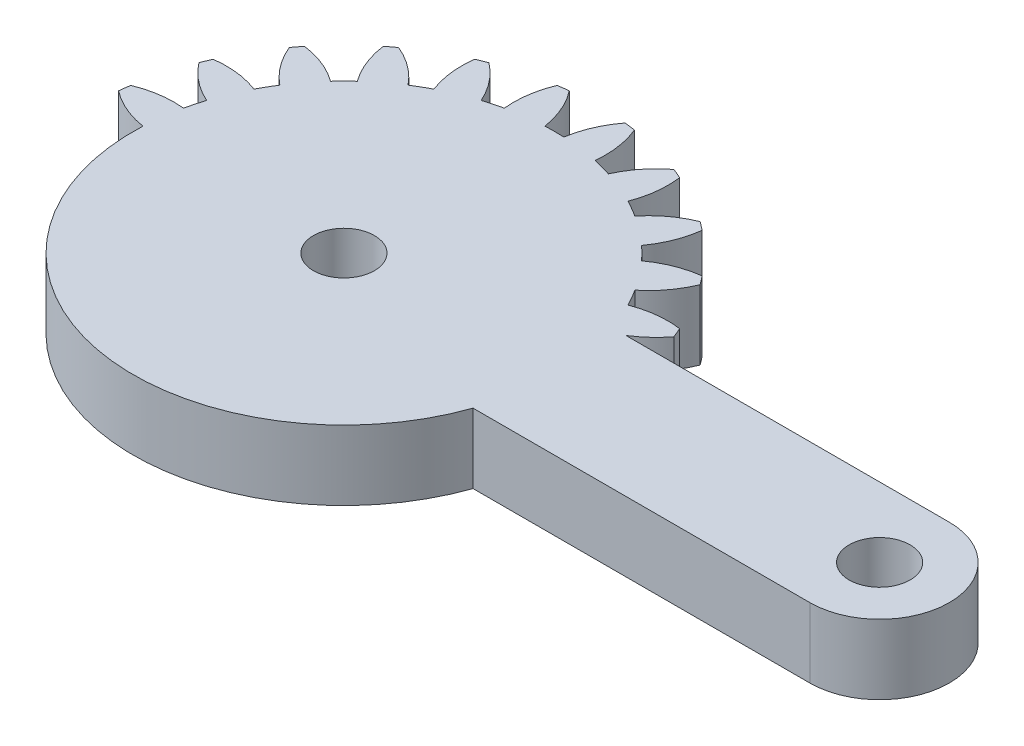
from build123d import *

# Parameters (mm, degrees)
SKETCH1_R           = 1.75
BOSS_EXTRUDE1_DEPTH = 4
CUT_EXTRUDE1_DEPTH  = 10


with BuildPart() as part:
    # Sketch1 → Boss-Extrude1 (new body)
    with BuildSketch(Plane(origin=(0, 0, 0), x_dir=(1, 0, 0), z_dir=(0, 1, 0))):
        with BuildLine():
            Line((20.643657446, 4), (2.081641936, 4))
            ThreePointArc((2.081641936, 4), (2.861028333, 4.588201733), (3.521749436, 5.30713988))
            ThreePointArc((3.521749436, 5.30713988), (3.405395609, 5.596745198), (3.282888305, 5.883801663))
            ThreePointArc((3.282888305, 5.883801663), (1.93527598, 5.894040025), (0.627094961, 5.57027124))
            ThreePointArc((0.627094961, 5.57027124), (0.366286148, 6.046375), (0.084372603, 6.510293938))
            ThreePointArc((0.084372603, 6.510293938), (1.018855105, 7.48132754), (1.683794586, 8.65351323))
            ThreePointArc((1.683794586, 8.65351323), (1.496450048, 8.903135899), (1.303821399, 9.148703928))
            ThreePointArc((1.303821399, 9.148703928), (-0.000522033, 8.809805691), (-1.180330337, 8.158486898))
            ThreePointArc((-1.180330337, 8.158486898), (-1.555477026, 8.550865528), (-1.947855656, 8.926012217))
            ThreePointArc((-1.947855656, 8.926012217), (-1.296536862, 10.105820521), (-0.957638625, 11.410163953))
            ThreePointArc((-0.957638625, 11.410163953), (-1.203206655, 11.602792602), (-1.452829324, 11.79013714))
            ThreePointArc((-1.452829324, 11.79013714), (-2.625015014, 11.125197659), (-3.596048616, 10.190715157))
            ThreePointArc((-3.596048616, 10.190715157), (-4.059967554, 10.472628702), (-4.536071314, 10.733437515))
            ThreePointArc((-4.536071314, 10.733437515), (-4.212302529, 12.041618533), (-4.222540891, 13.389230859))
            ThreePointArc((-4.222540891, 13.389230859), (-4.509597355, 13.511738163), (-4.799202674, 13.62809199))
            ThreePointArc((-4.799202674, 13.62809199), (-5.759348103, 12.682425791), (-6.455432668, 11.528463019))
            ThreePointArc((-6.455432668, 11.528463019), (-6.976508546, 11.680699536), (-7.503891752, 11.809396783))
            ThreePointArc((-7.503891752, 11.809396783), (-7.529737283, 13.156800143), (-7.888414517, 14.455843809))
            ThreePointArc((-7.888414517, 14.455843809), (-8.197396993, 14.499881098), (-8.507248835, 14.537314892))
            ThreePointArc((-8.507248835, 14.537314892), (-9.18992168, 13.375367565), (-9.563620196, 12.080565177))
            ThreePointArc((-9.563620196, 12.080565177), (-10.106342554, 12.09275), (-10.649064912, 12.080565177))
            ThreePointArc((-10.649064912, 12.080565177), (-11.022763428, 13.375367565), (-11.705436272, 14.537314892))
            ThreePointArc((-11.705436272, 14.537314892), (-12.015288115, 14.499881098), (-12.324270591, 14.455843809))
            ThreePointArc((-12.324270591, 14.455843809), (-12.682947825, 13.156800143), (-12.708793355, 11.809396783))
            ThreePointArc((-12.708793355, 11.809396783), (-13.236176561, 11.680699536), (-13.757252439, 11.528463019))
            ThreePointArc((-13.757252439, 11.528463019), (-14.453337005, 12.682425791), (-15.413482434, 13.62809199))
            ThreePointArc((-15.413482434, 13.62809199), (-15.703087752, 13.511738163), (-15.990144217, 13.389230859))
            ThreePointArc((-15.990144217, 13.389230859), (-16.000382579, 12.041618533), (-15.676613793, 10.733437515))
            ThreePointArc((-15.676613793, 10.733437515), (-16.152717554, 10.472628702), (-16.616636492, 10.190715157))
            ThreePointArc((-16.616636492, 10.190715157), (-17.587670094, 11.125197659), (-18.759855783, 11.79013714))
            ThreePointArc((-18.759855783, 11.79013714), (-19.009478453, 11.602792602), (-19.255046482, 11.410163953))
            ThreePointArc((-19.255046482, 11.410163953), (-18.916148245, 10.105820521), (-18.264829452, 8.926012217))
            ThreePointArc((-18.264829452, 8.926012217), (-18.657208082, 8.550865528), (-19.032354771, 8.158486898))
            ThreePointArc((-19.032354771, 8.158486898), (-20.212163074, 8.809805691), (-21.516506507, 9.148703928))
            ThreePointArc((-21.516506507, 9.148703928), (-21.709135156, 8.903135899), (-21.896479694, 8.65351323))
            ThreePointArc((-21.896479694, 8.65351323), (-21.231540213, 7.48132754), (-20.297057711, 6.510293938))
            ThreePointArc((-20.297057711, 6.510293938), (-20.578971255, 6.046375), (-20.839780068, 5.57027124))
            ThreePointArc((-20.839780068, 5.57027124), (-22.147961087, 5.894040025), (-23.495573413, 5.883801663))
            ThreePointArc((-23.495573413, 5.883801663), (-23.618080717, 5.596745198), (-23.734434544, 5.30713988))
            ThreePointArc((-23.734434544, 5.30713988), (-22.788768345, 4.346994451), (-21.634805572, 3.650909885))
            ThreePointArc((-21.634805572, 3.650909885), (-21.78704209, 3.129834008), (-21.915739337, 2.602450802))
            ThreePointArc((-21.915739337, 2.602450802), (-23.263142697, 2.576605271), (-24.562186363, 2.217928037))
            ThreePointArc((-24.562186363, 2.217928037), (-24.606223651, 1.908945561), (-24.643657446, 1.599093719))
            ThreePointArc((-24.643657446, 1.599093719), (-23.481710119, 0.916420874), (-22.186907731, 0.542722358))
            ThreePointArc((-22.186907731, 0.542722358), (-22.199092554, 0), (-22.186907731, -0.542722358))
            ThreePointArc((-22.186907731, -0.542722358), (-23.481710119, -0.916420874), (-24.643657446, -1.599093719))
            ThreePointArc((-24.643657446, -1.599093719), (-24.606223651, -1.908945561), (-24.562186363, -2.217928037))
            ThreePointArc((-24.562186363, -2.217928037), (-23.263142697, -2.576605271), (-21.915739337, -2.602450802))
            ThreePointArc((-21.915739337, -2.602450802), (-21.78704209, -3.129834008), (-21.634805572, -3.650909885))
            ThreePointArc((-21.634805572, -3.650909885), (-22.788768345, -4.346994451), (-23.734434544, -5.30713988))
            ThreePointArc((-23.734434544, -5.30713988), (-23.618080717, -5.596745198), (-23.495573413, -5.883801663))
            ThreePointArc((-23.495573413, -5.883801663), (-22.147961087, -5.894040025), (-20.839780068, -5.57027124))
            ThreePointArc((-20.839780068, -5.57027124), (-20.578971255, -6.046375), (-20.297057711, -6.510293938))
            ThreePointArc((-20.297057711, -6.510293938), (-21.231540213, -7.48132754), (-21.896479694, -8.65351323))
            ThreePointArc((-21.896479694, -8.65351323), (-21.709135156, -8.903135899), (-21.516506507, -9.148703928))
            ThreePointArc((-21.516506507, -9.148703928), (-20.212163074, -8.809805691), (-19.032354771, -8.158486898))
            ThreePointArc((-19.032354771, -8.158486898), (-18.657208082, -8.550865528), (-18.264829452, -8.926012217))
            ThreePointArc((-18.264829452, -8.926012217), (-18.916148245, -10.105820521), (-19.255046482, -11.410163953))
            ThreePointArc((-19.255046482, -11.410163953), (-19.009478453, -11.602792602), (-18.759855783, -11.79013714))
            ThreePointArc((-18.759855783, -11.79013714), (-17.587670094, -11.125197659), (-16.616636492, -10.190715157))
            ThreePointArc((-16.616636492, -10.190715157), (-16.152717554, -10.472628702), (-15.676613793, -10.733437515))
            ThreePointArc((-15.676613793, -10.733437515), (-16.000382579, -12.041618533), (-15.990144217, -13.389230859))
            ThreePointArc((-15.990144217, -13.389230859), (-15.703087752, -13.511738163), (-15.413482434, -13.62809199))
            ThreePointArc((-15.413482434, -13.62809199), (-14.453337005, -12.682425791), (-13.757252439, -11.528463019))
            ThreePointArc((-13.757252439, -11.528463019), (-13.236176561, -11.680699536), (-12.708793355, -11.809396783))
            ThreePointArc((-12.708793355, -11.809396783), (-12.682947825, -13.156800143), (-12.324270591, -14.455843809))
            ThreePointArc((-12.324270591, -14.455843809), (-12.015288115, -14.499881098), (-11.705436272, -14.537314892))
            ThreePointArc((-11.705436272, -14.537314892), (-11.022763428, -13.375367565), (-10.649064912, -12.080565177))
            ThreePointArc((-10.649064912, -12.080565177), (-10.106342554, -12.09275), (-9.563620196, -12.080565177))
            ThreePointArc((-9.563620196, -12.080565177), (-9.18992168, -13.375367565), (-8.507248835, -14.537314892))
            ThreePointArc((-8.507248835, -14.537314892), (-8.197396993, -14.499881098), (-7.888414517, -14.455843809))
            ThreePointArc((-7.888414517, -14.455843809), (-7.529737283, -13.156800143), (-7.503891752, -11.809396783))
            ThreePointArc((-7.503891752, -11.809396783), (-6.976508546, -11.680699536), (-6.455432668, -11.528463019))
            ThreePointArc((-6.455432668, -11.528463019), (-5.759348103, -12.682425791), (-4.799202674, -13.62809199))
            ThreePointArc((-4.799202674, -13.62809199), (-4.509597355, -13.511738163), (-4.222540891, -13.389230859))
            ThreePointArc((-4.222540891, -13.389230859), (-4.212302529, -12.041618533), (-4.536071314, -10.733437515))
            ThreePointArc((-4.536071314, -10.733437515), (-4.059967554, -10.472628702), (-3.596048616, -10.190715157))
            ThreePointArc((-3.596048616, -10.190715157), (-2.625015014, -11.125197659), (-1.452829324, -11.79013714))
            ThreePointArc((-1.452829324, -11.79013714), (-1.203206655, -11.602792602), (-0.957638625, -11.410163953))
            ThreePointArc((-0.957638625, -11.410163953), (-1.296536862, -10.105820521), (-1.947855656, -8.926012217))
            ThreePointArc((-1.947855656, -8.926012217), (-1.555477026, -8.550865528), (-1.180330337, -8.158486898))
            ThreePointArc((-1.180330337, -8.158486898), (-0.000522033, -8.809805691), (1.303821399, -9.148703928))
            ThreePointArc((1.303821399, -9.148703928), (1.496450048, -8.903135899), (1.683794586, -8.65351323))
            ThreePointArc((1.683794586, -8.65351323), (1.018855105, -7.48132754), (0.084372603, -6.510293938))
            ThreePointArc((0.084372603, -6.510293938), (0.366286148, -6.046375), (0.627094961, -5.57027124))
            ThreePointArc((0.627094961, -5.57027124), (1.93527598, -5.894040025), (3.282888305, -5.883801663))
            ThreePointArc((3.282888305, -5.883801663), (3.405395609, -5.596745198), (3.521749436, -5.30713988))
            ThreePointArc((3.521749436, -5.30713988), (2.861028333, -4.588201733), (2.081641936, -4))
            Line((2.081641936, -4), (20.643657446, -4))
            ThreePointArc((20.643657446, -4), (24.643657446, 0), (20.643657446, 4))
        make_face()
        with Locations((-10.106342554, 0)):
            Circle(SKETCH1_R, mode=Mode.SUBTRACT)
        with Locations((20.643657446, 0)):
            Circle(SKETCH1_R, mode=Mode.SUBTRACT)
    extrude(amount=BOSS_EXTRUDE1_DEPTH)

    # Sketch2 → Cut-Extrude1 (cut)
    with BuildSketch(Plane(origin=(0, 4, 0), x_dir=(1, 0, 0), z_dir=(0, 1, 0))):
        with BuildLine():
            ThreePointArc((-24.562186363, -2.217928037), (-23.263142697, -2.576605271), (-21.915739337, -2.602450802))
            ThreePointArc((-21.915739337, -2.602450802), (-22.095637401, -1.578420611), (-22.186907731, -0.542722358))
            ThreePointArc((-22.186907731, -0.542722358), (-23.481710119, -0.916420874), (-24.643657446, -1.599093719))
            ThreePointArc((-24.643657446, -1.599093719), (-24.606223651, -1.908945561), (-24.562186363, -2.217928037))
        make_face()
        with BuildLine():
            ThreePointArc((-23.495573413, -5.883801663), (-22.147961087, -5.894040025), (-20.839780068, -5.57027124))
            ThreePointArc((-20.839780068, -5.57027124), (-21.278586771, -4.627695077), (-21.634805572, -3.650909885))
            ThreePointArc((-21.634805572, -3.650909885), (-22.788768345, -4.346994451), (-23.734434544, -5.30713988))
            ThreePointArc((-23.734434544, -5.30713988), (-23.618080717, -5.596745198), (-23.495573413, -5.883801663))
        make_face()
        with BuildLine():
            ThreePointArc((-21.516506507, -9.148703928), (-20.212163074, -8.809805691), (-19.032354771, -8.158486898))
            ThreePointArc((-19.032354771, -8.158486898), (-19.70016616, -7.361599771), (-20.297057711, -6.510293938))
            ThreePointArc((-20.297057711, -6.510293938), (-21.231540213, -7.48132754), (-21.896479694, -8.65351323))
            ThreePointArc((-21.896479694, -8.65351323), (-21.709135156, -8.903135899), (-21.516506507, -9.148703928))
        make_face()
        with BuildLine():
            ThreePointArc((-18.759855783, -11.79013714), (-17.587670094, -11.125197659), (-16.616636492, -10.190715157))
            ThreePointArc((-16.616636492, -10.190715157), (-17.467942324, -9.593823606), (-18.264829452, -8.926012217))
            ThreePointArc((-18.264829452, -8.926012217), (-18.916148245, -10.105820521), (-19.255046482, -11.410163953))
            ThreePointArc((-19.255046482, -11.410163953), (-19.009478453, -11.602792602), (-18.759855783, -11.79013714))
        make_face()
        with BuildLine():
            ThreePointArc((-15.413482434, -13.62809199), (-14.453337005, -12.682425791), (-13.757252439, -11.528463019))
            ThreePointArc((-13.757252439, -11.528463019), (-14.734037631, -11.172244217), (-15.676613793, -10.733437515))
            ThreePointArc((-15.676613793, -10.733437515), (-16.000382579, -12.041618533), (-15.990144217, -13.389230859))
            ThreePointArc((-15.990144217, -13.389230859), (-15.703087752, -13.511738163), (-15.413482434, -13.62809199))
        make_face()
        with BuildLine():
            ThreePointArc((-11.705436272, -14.537314892), (-11.022763428, -13.375367565), (-10.649064912, -12.080565177))
            ThreePointArc((-10.649064912, -12.080565177), (-11.684763165, -11.989294847), (-12.708793355, -11.809396783))
            ThreePointArc((-12.708793355, -11.809396783), (-12.682947825, -13.156800143), (-12.324270591, -14.455843809))
            ThreePointArc((-12.324270591, -14.455843809), (-12.015288115, -14.499881098), (-11.705436272, -14.537314892))
        make_face()
        with BuildLine():
            ThreePointArc((-7.888414517, -14.455843809), (-7.529737283, -13.156800143), (-7.503891752, -11.809396783))
            ThreePointArc((-7.503891752, -11.809396783), (-8.527921943, -11.989294847), (-9.563620196, -12.080565177))
            ThreePointArc((-9.563620196, -12.080565177), (-9.18992168, -13.375367565), (-8.507248835, -14.537314892))
            ThreePointArc((-8.507248835, -14.537314892), (-8.197396993, -14.499881098), (-7.888414517, -14.455843809))
        make_face()
        with BuildLine():
            ThreePointArc((-4.222540891, -13.389230859), (-4.212302529, -12.041618533), (-4.536071314, -10.733437515))
            ThreePointArc((-4.536071314, -10.733437515), (-5.478647477, -11.172244217), (-6.455432668, -11.528463019))
            ThreePointArc((-6.455432668, -11.528463019), (-5.759348103, -12.682425791), (-4.799202674, -13.62809199))
            ThreePointArc((-4.799202674, -13.62809199), (-4.509597355, -13.511738163), (-4.222540891, -13.389230859))
        make_face()
        with BuildLine():
            ThreePointArc((-0.957638625, -11.410163953), (-1.296536862, -10.105820521), (-1.947855656, -8.926012217))
            ThreePointArc((-1.947855656, -8.926012217), (-2.744742783, -9.593823606), (-3.596048616, -10.190715157))
            ThreePointArc((-3.596048616, -10.190715157), (-2.625015014, -11.125197659), (-1.452829324, -11.79013714))
            ThreePointArc((-1.452829324, -11.79013714), (-1.203206655, -11.602792602), (-0.957638625, -11.410163953))
        make_face()
        with BuildLine():
            ThreePointArc((1.683794586, -8.65351323), (1.018855105, -7.48132754), (0.084372603, -6.510293938))
            ThreePointArc((0.084372603, -6.510293938), (-0.512518948, -7.361599771), (-1.180330337, -8.158486898))
            ThreePointArc((-1.180330337, -8.158486898), (-0.000522033, -8.809805691), (1.303821399, -9.148703928))
            ThreePointArc((1.303821399, -9.148703928), (1.496450048, -8.903135899), (1.683794586, -8.65351323))
        make_face()
        with BuildLine():
            ThreePointArc((3.521749436, -5.30713988), (2.861028333, -4.588201733), (2.081641936, -4))
            Line((2.081641936, -4), (1.305695063, -4))
            ThreePointArc((1.305695063, -4), (0.994195953, -4.797149927), (0.627094961, -5.57027124))
            ThreePointArc((0.627094961, -5.57027124), (1.93527598, -5.894040025), (3.282888305, -5.883801663))
            ThreePointArc((3.282888305, -5.883801663), (3.405395609, -5.596745198), (3.521749436, -5.30713988))
        make_face()
    extrude(amount=-CUT_EXTRUDE1_DEPTH, mode=Mode.SUBTRACT)


solid = part.part
